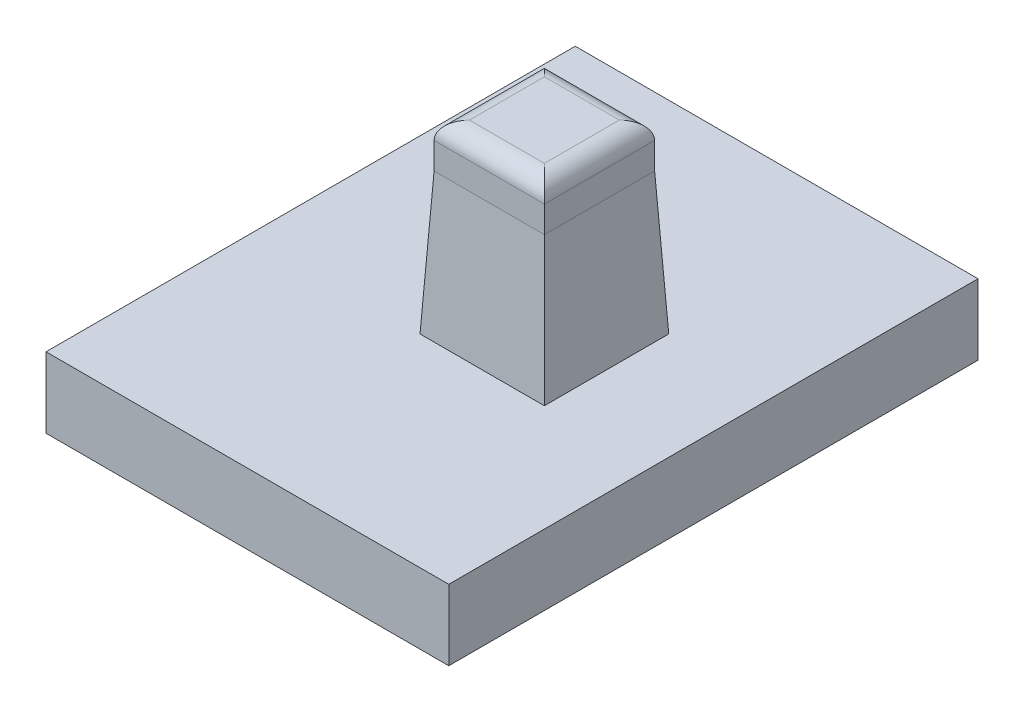
from build123d import *

# Parameters (mm, degrees)
SKETCH1_W                = 240
SKETCH1_H                = 30
SKETCH1_W_2              = 6.25
SKETCH1_H_2              = 6.25
BOSS_EXTRUDE1_DEPTH      = 4
SKETCH2_W                = 6.25
SKETCH2_H                = 6.25
BOSS_EXTRUDE2_DEPTH      = 10.5
BOSS_EXTRUDE2_DEPTH_BACK = 4
SKETCH3_W                = 222.243091979
SKETCH3_H                = 95.437848018
CUT_EXTRUDE1_DEPTH       = 11.5
CUT_EXTRUDE1_DEPTH_BACK  = 5
FILLET1_R                = 1
CHAMFER1_SIZE            = 0.4
CHAMFER1_SIZE2           = 8


with BuildPart() as part:
    # Sketch1 → Boss-Extrude1 (new body)
    with BuildSketch(Plane(origin=(0, 0, 0), x_dir=(1, 0, 0), z_dir=(0, 1, 0))):
        with Locations((120, 15)):
            Rectangle(SKETCH1_W, SKETCH1_H)
        with Locations((13.25, 15)):
            Rectangle(SKETCH1_W_2, SKETCH1_H_2, mode=Mode.SUBTRACT)
        with Locations((43.75, 15)):
            Rectangle(SKETCH1_W_2, SKETCH1_H_2, mode=Mode.SUBTRACT)
        with Locations((74.25, 15)):
            Rectangle(SKETCH1_W_2, SKETCH1_H_2, mode=Mode.SUBTRACT)
        with Locations((104.75, 15)):
            Rectangle(SKETCH1_W_2, SKETCH1_H_2, mode=Mode.SUBTRACT)
        with Locations((135.25, 15)):
            Rectangle(SKETCH1_W_2, SKETCH1_H_2, mode=Mode.SUBTRACT)
        with Locations((165.75, 15)):
            Rectangle(SKETCH1_W_2, SKETCH1_H_2, mode=Mode.SUBTRACT)
        with Locations((196.25, 15)):
            Rectangle(SKETCH1_W_2, SKETCH1_H_2, mode=Mode.SUBTRACT)
        with Locations((226.75, 15)):
            Rectangle(SKETCH1_W_2, SKETCH1_H_2, mode=Mode.SUBTRACT)
    extrude(amount=BOSS_EXTRUDE1_DEPTH)

    # Sketch2 → Boss-Extrude2 (add, two sides)
    with BuildSketch(Plane(origin=(0, 4, 0), x_dir=(1, 0, 0), z_dir=(0, 1, 0))) as boss_extrude2_sk:
        with Locations((13.25, 15)):
            Rectangle(SKETCH2_W, SKETCH2_H)
        with Locations((43.75, 15)):
            Rectangle(SKETCH2_W, SKETCH2_H)
        with Locations((74.25, 15)):
            Rectangle(SKETCH2_W, SKETCH2_H)
        with Locations((104.75, 15)):
            Rectangle(SKETCH2_W, SKETCH2_H)
        with Locations((135.25, 15)):
            Rectangle(SKETCH2_W, SKETCH2_H)
        with Locations((165.75, 15)):
            Rectangle(SKETCH2_W, SKETCH2_H)
        with Locations((196.25, 15)):
            Rectangle(SKETCH2_W, SKETCH2_H)
        with Locations((226.75, 15)):
            Rectangle(SKETCH2_W, SKETCH2_H)
    extrude(amount=BOSS_EXTRUDE2_DEPTH)
    extrude(boss_extrude2_sk.sketch, amount=-BOSS_EXTRUDE2_DEPTH_BACK)

    # Sketch3 → Cut-Extrude1 (cut, two sides)
    with BuildSketch(Plane(origin=(0, 4, 0), x_dir=(1, 0, 0), z_dir=(0, 1, 0))) as cut_extrude1_sk:
        with Locations((133.951037232, 10.683129124)):
            Rectangle(SKETCH3_W, SKETCH3_H)
    extrude(amount=CUT_EXTRUDE1_DEPTH, mode=Mode.SUBTRACT)
    extrude(cut_extrude1_sk.sketch, amount=-CUT_EXTRUDE1_DEPTH_BACK, mode=Mode.SUBTRACT)

    # Fillet1
    fillet1_edges = [part.edges().sort_by_distance(p)[0] for p in [
        (10.125, 14.5, -15),
        (13.25, 14.5, -11.875),
        (16.375, 14.5, -15),
        (13.25, 14.5, -18.125),
    ]]
    fillet(fillet1_edges, radius=FILLET1_R)

    # Chamfer1
    chamfer1_edges = [part.edges().sort_by_distance(p)[0] for p in [
        (10.125, 4, -15),
        (13.25, 4, -11.875),
        (16.375, 4, -15),
        (13.25, 4, -18.125),
    ]]
    chamfer1_side = [part.faces().sort_by_distance(p)[0] for p in [
        (0.376986163, 4, -15),
    ]]
    chamfer(chamfer1_edges, length=CHAMFER1_SIZE, length2=CHAMFER1_SIZE2, reference=chamfer1_side[0])


solid = part.part
